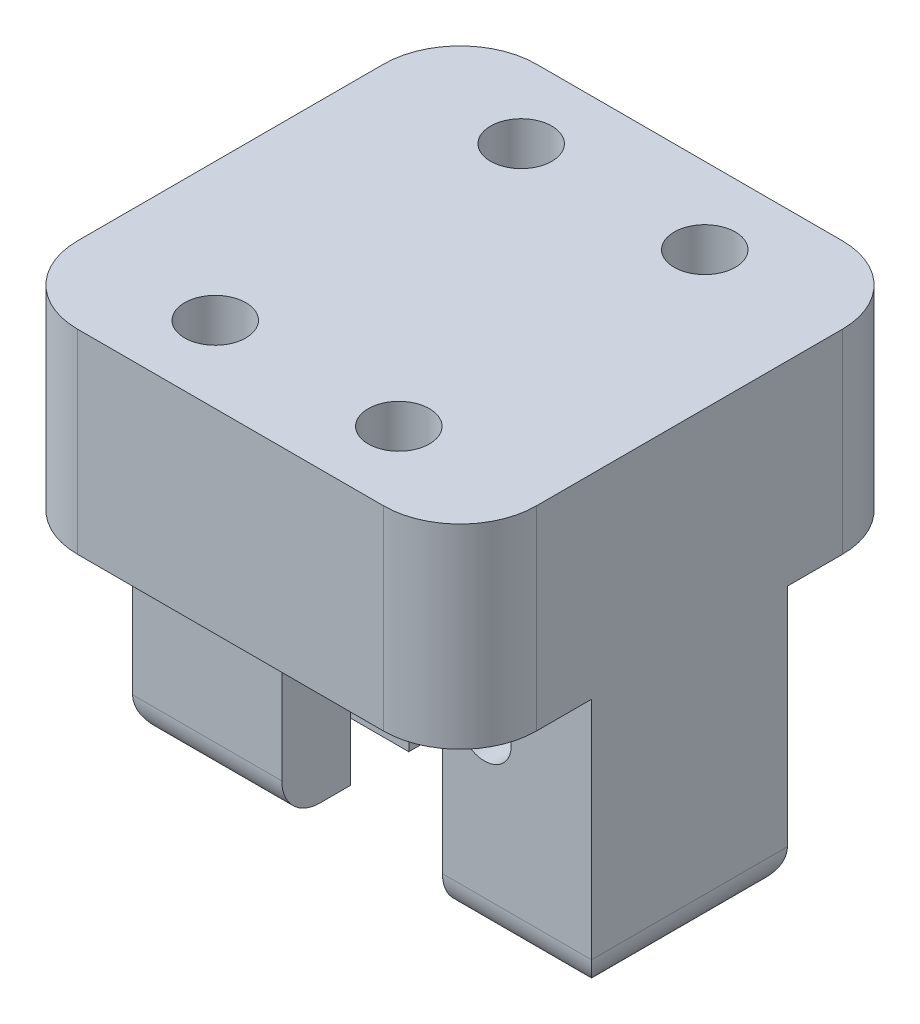
from build123d import *

# Parameters (mm, degrees)
SKETCH2_W               = 30
SKETCH2_H               = 30
BOSS_EXTRUDE1_DEPTH     = 30
CUT_EXTRUDE1_REACH      = 47
SKETCH3_R               = 1.75
CUT_EXTRUDE2_START      = -15
SKETCH4_R               = 1.75
CUT_EXTRUDE2_DEPTH      = 1.9
CUT_EXTRUDE2_DEPTH_BACK = 1.9
CUT_EXTRUDE3_REACH      = 38.742
SKETCH5_R               = 2
SKETCH6_W               = 30
SKETCH6_H               = 8.6
CUT_EXTRUDE5_DEPTH      = 17.25
SKETCH8_R               = 3.6
CUT_EXTRUDE6_DEPTH      = 2
FILLET1_R               = 5
FILLET2_R               = 2.5


with BuildPart() as part:
    # Sketch2 → Boss-Extrude1 (new body)
    with BuildSketch(Plane(origin=(0, 0, 0), x_dir=(1, 0, 0), z_dir=(0, 1, 0))):
        Rectangle(SKETCH2_W, SKETCH2_H)
    extrude(amount=BOSS_EXTRUDE1_DEPTH)

    # Sketch3 → Cut-Extrude1 (cut, up to next)
    with BuildSketch(Plane.XY.offset(15), mode=Mode.PRIVATE) as cut_extrude1_sk1:
        with Locations((-8, 12)):
            Circle(SKETCH3_R)
    cut_extrude1_tool1 = extrude(cut_extrude1_sk1.sketch, amount=-CUT_EXTRUDE1_REACH, mode=Mode.PRIVATE) & part.part
    # Sketch3 → Cut-Extrude1 (cut, up to next)
    with BuildSketch(Plane.XY.offset(15), mode=Mode.PRIVATE) as cut_extrude1_sk2:
        with Locations((8, 12)):
            Circle(SKETCH3_R)
    cut_extrude1_tool2 = extrude(cut_extrude1_sk2.sketch, amount=-CUT_EXTRUDE1_REACH, mode=Mode.PRIVATE) & part.part
    # Sketch3 → Cut-Extrude1 (cut, up to next)
    with BuildSketch(Plane.XY.offset(15), mode=Mode.PRIVATE) as cut_extrude1_sk3:
        with BuildLine():
            ThreePointArc((5.25, 12), (0, 17.25), (-5.25, 12))
            Line((-5.25, 12), (5.25, 12))
        make_face()
    cut_extrude1_tool3 = extrude(cut_extrude1_sk3.sketch, amount=-CUT_EXTRUDE1_REACH, mode=Mode.PRIVATE) & part.part
    # Sketch3 → Cut-Extrude1 (cut, up to next)
    with BuildSketch(Plane.XY.offset(15), mode=Mode.PRIVATE) as cut_extrude1_sk4:
        with BuildLine():
            Line((5.25, 12), (-5.25, 12))
            ThreePointArc((-5.25, 12), (0, 6.75), (5.25, 12))
        make_face()
    cut_extrude1_tool4 = extrude(cut_extrude1_sk4.sketch, amount=-CUT_EXTRUDE1_REACH, mode=Mode.PRIVATE) & part.part
    # Sketch3 → Cut-Extrude1 (cut, up to next)
    with BuildSketch(Plane.XY.offset(15), mode=Mode.PRIVATE) as cut_extrude1_sk5:
        with BuildLine():
            ThreePointArc((5.25, 12), (0, 17.25), (-5.25, 12))
            Line((-5.25, 12), (5.25, 12))
        make_face()
    cut_extrude1_tool5 = extrude(cut_extrude1_sk5.sketch, amount=-CUT_EXTRUDE1_REACH, mode=Mode.PRIVATE) & part.part
    # Sketch3 → Cut-Extrude1 (cut, up to next)
    with BuildSketch(Plane.XY.offset(15), mode=Mode.PRIVATE) as cut_extrude1_sk6:
        with BuildLine():
            Line((5.25, 12), (-5.25, 12))
            ThreePointArc((-5.25, 12), (0, 6.75), (5.25, 12))
        make_face()
    cut_extrude1_tool6 = extrude(cut_extrude1_sk6.sketch, amount=-CUT_EXTRUDE1_REACH, mode=Mode.PRIVATE) & part.part
    # Sketch3 → Cut-Extrude1 (cut, up to next)
    with BuildSketch(Plane.XY.offset(15), mode=Mode.PRIVATE) as cut_extrude1_sk7:
        with BuildLine():
            ThreePointArc((5.25, 12), (0, 6.75), (-5.25, 12))
            Line((-5.25, 12), (-5.25, 0))
            Line((-5.25, 0), (5.25, 0))
            Line((5.25, 0), (5.25, 12))
        make_face()
    cut_extrude1_tool7 = extrude(cut_extrude1_sk7.sketch, amount=-CUT_EXTRUDE1_REACH, mode=Mode.PRIVATE) & part.part
    add(cut_extrude1_tool1.solids().sort_by_distance((-8, 12, 15))[0], mode=Mode.SUBTRACT)
    add(cut_extrude1_tool2.solids().sort_by_distance((8, 12, 15))[0], mode=Mode.SUBTRACT)
    add(cut_extrude1_tool3.solids().sort_by_distance((0, 14.228169, 15))[0], mode=Mode.SUBTRACT)
    add(cut_extrude1_tool4.solids().sort_by_distance((0, 9.771831, 15))[0], mode=Mode.SUBTRACT)
    add(cut_extrude1_tool5.solids().sort_by_distance((0, 14.228169, 15))[0], mode=Mode.SUBTRACT)
    add(cut_extrude1_tool6.solids().sort_by_distance((0, 9.771831, 15))[0], mode=Mode.SUBTRACT)
    add(cut_extrude1_tool7.solids().sort_by_distance((0, 4.02549, 15))[0], mode=Mode.SUBTRACT)

    # Sketch4 → Cut-Extrude2 (cut, two sides)
    with BuildSketch(Plane.XY.offset(15).offset(CUT_EXTRUDE2_START)) as cut_extrude2_sk:
        with BuildLine():
            Line((-5.25, 0), (-5.25, 12))
            ThreePointArc((-5.25, 12), (0, 17.25), (5.25, 12))
            Line((5.25, 12), (5.25, 0))
            Line((5.25, 0), (11.25, 0))
            Line((11.25, 0), (11.25, 12))
            ThreePointArc((11.25, 12), (0, 23.25), (-11.25, 12))
            Line((-11.25, 12), (-11.25, 0))
            Line((-11.25, 0), (-5.25, 0))
        make_face()
        with Locations((8, 12)):
            Circle(SKETCH4_R, mode=Mode.SUBTRACT)
        with Locations((-8, 12)):
            Circle(SKETCH4_R, mode=Mode.SUBTRACT)
    extrude(amount=CUT_EXTRUDE2_DEPTH, mode=Mode.SUBTRACT)
    extrude(cut_extrude2_sk.sketch, amount=-CUT_EXTRUDE2_DEPTH_BACK, mode=Mode.SUBTRACT)

    # Sketch5 → Cut-Extrude3 (cut, up to next)
    with BuildSketch(Plane(origin=(0, 30, 0), x_dir=(1, 0, 0), z_dir=(0, 1, 0)), mode=Mode.PRIVATE) as cut_extrude3_sk1:
        with Locations(Location((-6, 10, 0), (0, 0, 270))):
            Circle(SKETCH5_R)
    cut_extrude3_tool1 = extrude(cut_extrude3_sk1.sketch, amount=-CUT_EXTRUDE3_REACH, mode=Mode.PRIVATE) & part.part
    # Sketch5 → Cut-Extrude3 (cut, up to next)
    with BuildSketch(Plane(origin=(0, 30, 0), x_dir=(1, 0, 0), z_dir=(0, 1, 0)), mode=Mode.PRIVATE) as cut_extrude3_sk2:
        with Locations(Location((6, 10, 0), (0, 0, 247.975687163))):
            Circle(SKETCH5_R)
    cut_extrude3_tool2 = extrude(cut_extrude3_sk2.sketch, amount=-CUT_EXTRUDE3_REACH, mode=Mode.PRIVATE) & part.part
    # Sketch5 → Cut-Extrude3 (cut, up to next)
    with BuildSketch(Plane(origin=(0, 30, 0), x_dir=(1, 0, 0), z_dir=(0, 1, 0)), mode=Mode.PRIVATE) as cut_extrude3_sk3:
        with Locations(Location((6, -10, 0), (0, 0, 270))):
            Circle(SKETCH5_R)
    cut_extrude3_tool3 = extrude(cut_extrude3_sk3.sketch, amount=-CUT_EXTRUDE3_REACH, mode=Mode.PRIVATE) & part.part
    # Sketch5 → Cut-Extrude3 (cut, up to next)
    with BuildSketch(Plane(origin=(0, 30, 0), x_dir=(1, 0, 0), z_dir=(0, 1, 0)), mode=Mode.PRIVATE) as cut_extrude3_sk4:
        with Locations(Location((-6, -10, 0), (0, 0, 292.024312837))):
            Circle(SKETCH5_R)
    cut_extrude3_tool4 = extrude(cut_extrude3_sk4.sketch, amount=-CUT_EXTRUDE3_REACH, mode=Mode.PRIVATE) & part.part
    add(cut_extrude3_tool1.solids().sort_by_distance((-6, 30, -10))[0], mode=Mode.SUBTRACT)
    add(cut_extrude3_tool2.solids().sort_by_distance((6, 30, -10))[0], mode=Mode.SUBTRACT)
    add(cut_extrude3_tool3.solids().sort_by_distance((6, 30, 10))[0], mode=Mode.SUBTRACT)
    add(cut_extrude3_tool4.solids().sort_by_distance((-6, 30, 10))[0], mode=Mode.SUBTRACT)

    # Sketch6 → Cut-Extrude5 (cut)
    with BuildSketch(Plane.XZ):
        with Locations((0, 10.7)):
            Rectangle(SKETCH6_W, SKETCH6_H)
        with Locations((0, -10.7)):
            Rectangle(SKETCH6_W, SKETCH6_H)
    extrude(amount=-CUT_EXTRUDE5_DEPTH, mode=Mode.SUBTRACT)

    # Sketch8 → Cut-Extrude6 (cut)
    with BuildSketch(Plane.XZ.offset(-17.25)):
        with Locations(Location((-6, 10, 0), (0, 0, 270))):
            Circle(SKETCH8_R)
        with Locations(Location((6, 10, 0), (0, 0, 270))):
            Circle(SKETCH8_R)
        with Locations(Location((6, -10, 0), (0, 0, 270))):
            Circle(SKETCH8_R)
        with Locations(Location((-6, -10, 0), (0, 0, 90))):
            Circle(SKETCH8_R)
    extrude(amount=-CUT_EXTRUDE6_DEPTH, mode=Mode.SUBTRACT)

    # Fillet1
    fillet1_edges = [part.edges().sort_by_distance(p)[0] for p in [
        (15, 23.625, 15),
        (-15, 23.625, 15),
        (-15, 23.625, -15),
        (15, 23.625, -15),
    ]]
    fillet(fillet1_edges, radius=FILLET1_R)

    # Fillet2
    fillet2_edges = [part.edges().sort_by_distance(p)[0] for p in [
        (-15, 0, 0),
        (15, 0, 0),
        (-10.125, 0, -6.4),
        (10.125, 0, -6.4),
        (-10.125, 0, 6.4),
        (10.125, 0, 6.4),
    ]]
    fillet(fillet2_edges, radius=FILLET2_R)


solid = part.part
